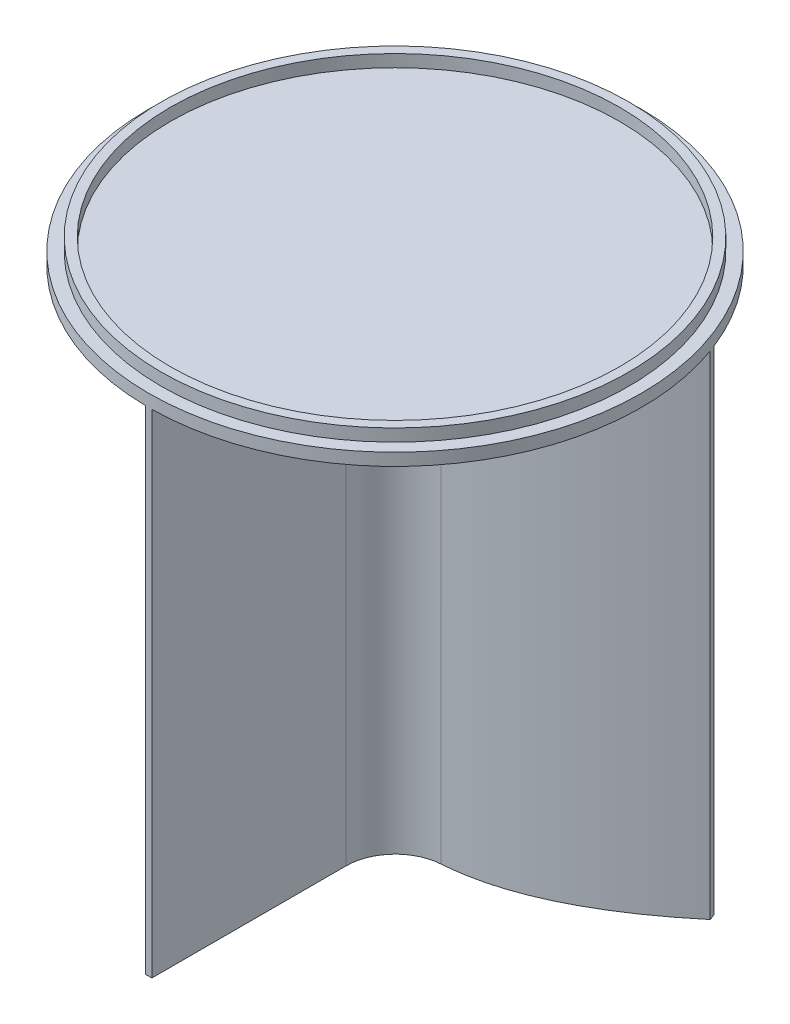
from build123d import *

# Parameters (mm, degrees)
SKETCH1_R           = 63.5
BOSS_EXTRUDE1_DEPTH = 3.175
SKETCH2_R           = 60.325
SKETCH2_R_2         = 57.94375
BOSS_EXTRUDE2_DEPTH = 3.175
BOSS_EXTRUDE3_DEPTH = 127
FILLET1_R           = 12.7


with BuildPart() as part:
    # Sketch1 → Boss-Extrude1 (new body)
    with BuildSketch(Plane(origin=(0, 0, 0), x_dir=(1, 0, 0), z_dir=(0, 1, 0))):
        Circle(SKETCH1_R)
    extrude(amount=BOSS_EXTRUDE1_DEPTH)

    # Sketch2 → Boss-Extrude2 (add)
    with BuildSketch(Plane(origin=(0, 3.175, 0), x_dir=(1, 0, 0), z_dir=(0, 1, 0))):
        Circle(SKETCH2_R)
        Circle(SKETCH2_R_2, mode=Mode.SUBTRACT)
    extrude(amount=BOSS_EXTRUDE2_DEPTH)

    # Sketch3 → Boss-Extrude3 (add)
    with BuildSketch(Plane.XZ):
        with BuildLine():
            Line((-0.79375, 63.495038869), (-0.79375, 0.165767528))
            add(Edge.make_bspline(
                [(-0.79375, 0.165767528), (-5.19662587, 0.926394102), (-12.028294814, 1.162164763), (-21.507708178, -0.414484498), (-28.959628823, -2.648391287), (-36.549761029, -5.897616417), (-42.990474773, -9.452796753), (-48.210003566, -12.80329328), (-52.163993282, -15.574258653), (-55.991469214, -18.475868316), (-58.550879749, -20.554822593), (-59.733413602, -21.544588636)],
                knots=[0.02237317, 0.02237317, 0.02237317, 0.02237317, 0.257875777, 0.382709096, 0.507542415, 0.632375733, 0.757209052, 0.819625711, 0.882042371, 0.94445903, 1.000095669, 1.000095669, 1.000095669, 1.000095669], degree=3))
            ThreePointArc((-59.733413602, -21.544588636), (-59.442577848, -22.334501085), (-59.141296843, -23.120488916))
            add(Edge.make_bspline(
                [(0, -1.594817249), (-4.497680515, -0.712511058), (-11.342121161, -0.373927815), (-20.797455162, -1.88480643), (-28.048219709, -4.011073511), (-35.464551173, -7.138170569), (-41.780862519, -10.584133838), (-46.914506534, -13.847671974), (-50.8035363, -16.548272657), (-54.079771454, -19.012705913), (-56.859334031, -21.22174097), (-58.343356695, -22.447695352), (-59.141296843, -23.120488916)],
                knots=[0.002745404, 0.002745404, 0.002745404, 0.002745404, 0.252059053, 0.376715878, 0.501372702, 0.626029527, 0.750686351, 0.813014763, 0.875343176, 0.937671588, 0.968835794, 1.006875689, 1.006875689, 1.006875689, 1.006875689], degree=3))
            add(Edge.make_bspline(
                [(59.141296843, -23.120488916), (58.343356695, -22.447695352), (56.859334031, -21.22174097), (54.079771454, -19.012705913), (50.8035363, -16.548272657), (46.914506534, -13.847671974), (41.780862519, -10.584133838), (35.464551173, -7.138170569), (28.048219709, -4.011073511), (20.797455162, -1.88480643), (11.342121161, -0.373927815), (4.497680515, -0.712511058), (0, -1.594817249)],
                knots=[-0.004130285, -0.004130285, -0.004130285, -0.004130285, 0.03390961, 0.065073816, 0.127402229, 0.189730641, 0.252059053, 0.376715878, 0.501372702, 0.626029527, 0.750686351, 1, 1, 1, 1], degree=3))
            ThreePointArc((59.141296843, -23.120488916), (59.442577848, -22.334501085), (59.733413602, -21.544588636))
            add(Edge.make_bspline(
                [(59.733413602, -21.544588636), (58.550879749, -20.554822593), (55.991469214, -18.475868316), (52.163993282, -15.574258653), (48.210003566, -12.80329328), (42.990474773, -9.452796753), (36.549761029, -5.897616417), (28.959628823, -2.648391287), (21.507708178, -0.414484498), (12.028294814, 1.162164763), (5.19662587, 0.926394102), (0.79375, 0.165767528)],
                knots=[0.002649735, 0.002649735, 0.002649735, 0.002649735, 0.058286374, 0.120703033, 0.183119693, 0.245536352, 0.370369671, 0.495202989, 0.620036308, 0.744869627, 0.980372234, 0.980372234, 0.980372234, 0.980372234], degree=3))
            Line((0.79375, 0.165767528), (0.79375, 63.495038869))
            ThreePointArc((0.79375, 63.495038869), (0, 63.5), (-0.79375, 63.495038869))
        make_face()
    extrude(amount=BOSS_EXTRUDE3_DEPTH)

    # Fillet1
    fillet1_edges = [part.edges().sort_by_distance(p)[0] for p in [
        (0.79375, -63.5, 0.165767528),
        (-0.79375, -63.5, 0.165767528),
    ]]
    fillet(fillet1_edges, radius=FILLET1_R)


solid = part.part
